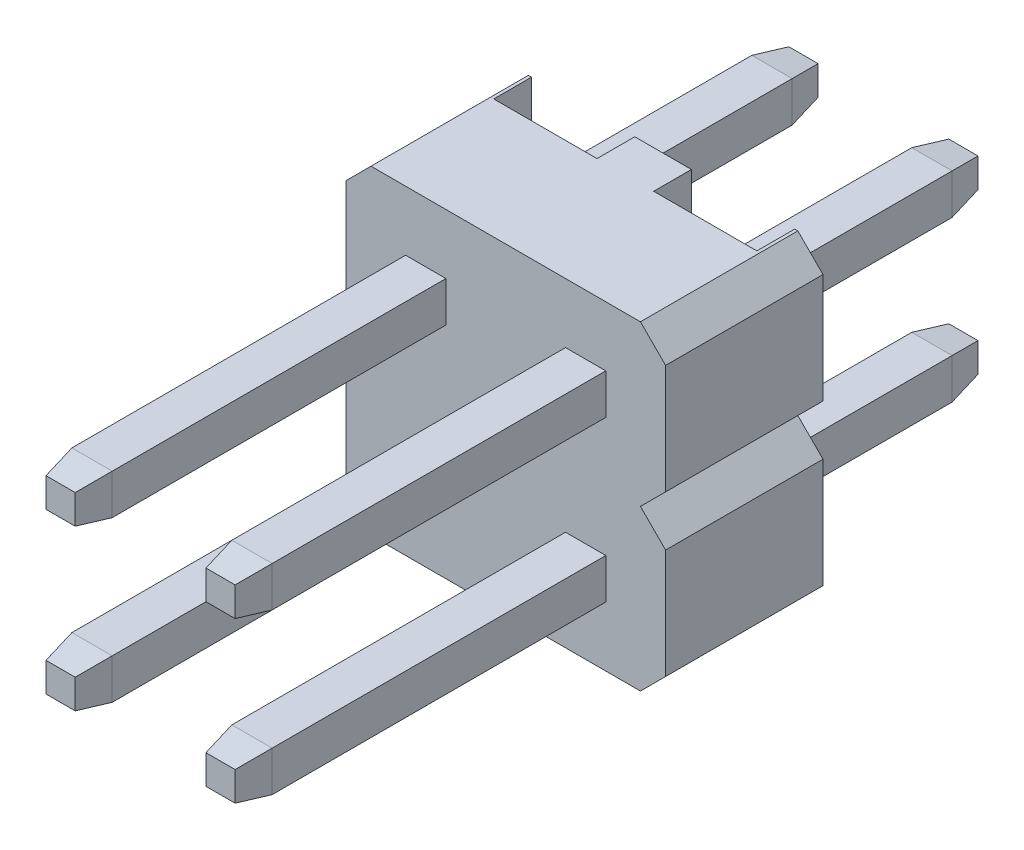
from build123d import *

# Parameters (mm, degrees)
SKETCH1_W             = 0.64
SKETCH1_H             = 0.64
BOSS_EXTRUDE1_DEPTH   = 5.3
BOSS_EXTRUDE1_2_DEPTH = 5.3
BOSS_EXTRUDE1_3_DEPTH = 5.3
BOSS_EXTRUDE1_4_DEPTH = 5.3
SKETCH2_W             = 0.64
SKETCH2_H             = 0.64
BOSS_EXTRUDE2_DEPTH   = 0.5
BOSS_EXTRUDE2_TAPER   = 10
BOSS_EXTRUDE3_DEPTH   = 2.5
SKETCH5_W             = 1.64
SKETCH5_H             = 5.08
CUT_EXTRUDE1_DEPTH    = 0.6
CUT_EXTRUDE3_DEPTH    = 3.5
SKETCH8_W             = 0.64
SKETCH8_H             = 0.64
BOSS_EXTRUDE4_DEPTH   = 3.6
BOSS_EXTRUDE4_2_DEPTH = 3.6
BOSS_EXTRUDE4_3_DEPTH = 3.6
BOSS_EXTRUDE4_4_DEPTH = 3.6
SKETCH9_W             = 0.64
SKETCH9_H             = 0.64
BOSS_EXTRUDE5_DEPTH   = 0.5
BOSS_EXTRUDE5_TAPER   = 10


with BuildPart() as part:
    # Sketch1 → Boss-Extrude1 (new body)
    with BuildSketch(Plane.XY):
        with Locations((-1.27, 1.27)):
            Rectangle(SKETCH1_W, SKETCH1_H)
    extrude(amount=BOSS_EXTRUDE1_DEPTH)



with BuildPart() as body_2:
    # Sketch1 → Boss-Extrude1 2 (new body)
    with BuildSketch(Plane.XY):
        with Locations((-1.27, -1.27)):
            Rectangle(SKETCH1_W, SKETCH1_H)
    extrude(amount=BOSS_EXTRUDE1_2_DEPTH)


with BuildPart() as body_3:
    # Sketch1 → Boss-Extrude1 3 (new body)
    with BuildSketch(Plane.XY):
        with Locations((1.27, 1.27)):
            Rectangle(SKETCH1_W, SKETCH1_H)
    extrude(amount=BOSS_EXTRUDE1_3_DEPTH)


with BuildPart() as body_4:
    # Sketch1 → Boss-Extrude1 4 (new body)
    with BuildSketch(Plane.XY):
        with Locations((1.27, -1.27)):
            Rectangle(SKETCH1_W, SKETCH1_H)
    extrude(amount=BOSS_EXTRUDE1_4_DEPTH)


with BuildPart() as part_1:
    add(part.part)

    add(body_2.part)  # Boss-Extrude2 merges body 2

    add(body_3.part)  # Boss-Extrude2 merges body 3

    add(body_4.part)  # Boss-Extrude2 merges body 4
    # Sketch2 → Boss-Extrude2 (add)
    with BuildSketch(Plane.XY.offset(5.3)):
        with Locations((-1.27, -1.27)):
            Rectangle(SKETCH2_W, SKETCH2_H)
        with Locations((-1.27, 1.27)):
            Rectangle(SKETCH2_W, SKETCH2_H)
        with Locations((1.27, -1.27)):
            Rectangle(SKETCH2_W, SKETCH2_H)
        with Locations((1.27, 1.27)):
            Rectangle(SKETCH2_W, SKETCH2_H)
    extrude(amount=BOSS_EXTRUDE2_DEPTH, taper=BOSS_EXTRUDE2_TAPER)


with BuildPart() as body_2_2:
    # Sketch3 → Boss-Extrude3 (new body)
    with BuildSketch(Plane.XY):
        Polygon((-2.14, 2.54), (2.14, 2.54), (2.54, 2.14), (2.54, -2.14), (2.14, -2.54), (-2.14, -2.54), (-2.54, -2.14), (-2.54, 2.14), align=None)
    extrude(amount=-BOSS_EXTRUDE3_DEPTH)

    # Sketch5 → Cut-Extrude1 (cut)
    with BuildSketch(Plane(origin=(0, 0, -2.5), x_dir=(-1, 0, 0), z_dir=(0, 0, -1))):
        with Locations((-1.27, 0)):
            Rectangle(SKETCH5_W, SKETCH5_H)
        with Locations((1.27, 0)):
            Rectangle(SKETCH5_W, SKETCH5_H)
    extrude(amount=-CUT_EXTRUDE1_DEPTH, mode=Mode.SUBTRACT)

    # Sketch7 → Cut-Extrude3 (cut, through all)
    with BuildSketch(Plane.XY):
        Polygon((2.54, 0), (2.54, 0.4), (2.14, 0), align=None)
        Polygon((2.54, 0), (2.14, 0), (2.54, -0.4), align=None)
        Polygon((-2.54, 0), (-2.54, -0.4), (-2.14, 0), align=None)
        Polygon((-2.54, 0.4), (-2.54, 0), (-2.14, 0), align=None)
    extrude(amount=-CUT_EXTRUDE3_DEPTH, mode=Mode.SUBTRACT)


with BuildPart() as body_3_2:
    # Sketch8 → Boss-Extrude4 (new body)
    with BuildSketch(Plane(origin=(0, 0, -1.9), x_dir=(-1, 0, 0), z_dir=(0, 0, -1))):
        with Locations((1.27, -1.27)):
            Rectangle(SKETCH8_W, SKETCH8_H)
    extrude(amount=BOSS_EXTRUDE4_DEPTH)



with BuildPart() as body_4_2:
    # Sketch8 → Boss-Extrude4 2 (new body)
    with BuildSketch(Plane(origin=(0, 0, -1.9), x_dir=(-1, 0, 0), z_dir=(0, 0, -1))):
        with Locations((1.27, 1.27)):
            Rectangle(SKETCH8_W, SKETCH8_H)
    extrude(amount=BOSS_EXTRUDE4_2_DEPTH)


with BuildPart() as body_5:
    # Sketch8 → Boss-Extrude4 3 (new body)
    with BuildSketch(Plane(origin=(0, 0, -1.9), x_dir=(-1, 0, 0), z_dir=(0, 0, -1))):
        with Locations((-1.27, 1.27)):
            Rectangle(SKETCH8_W, SKETCH8_H)
    extrude(amount=BOSS_EXTRUDE4_3_DEPTH)


with BuildPart() as body_6:
    # Sketch8 → Boss-Extrude4 4 (new body)
    with BuildSketch(Plane(origin=(0, 0, -1.9), x_dir=(-1, 0, 0), z_dir=(0, 0, -1))):
        with Locations((-1.27, -1.27)):
            Rectangle(SKETCH8_W, SKETCH8_H)
    extrude(amount=BOSS_EXTRUDE4_4_DEPTH)


with BuildPart() as body_3_2_1:
    add(body_3_2.part)

    add(body_4_2.part)  # Boss-Extrude5 merges body 4 2

    add(body_5.part)  # Boss-Extrude5 merges body 5

    add(body_6.part)  # Boss-Extrude5 merges body 6
    # Sketch9 → Boss-Extrude5 (add)
    with BuildSketch(Plane(origin=(0, 0, -5.5), x_dir=(-1, 0, 0), z_dir=(0, 0, -1))):
        with Locations((1.27, 1.27)):
            Rectangle(SKETCH9_W, SKETCH9_H)
        with Locations((1.27, -1.27)):
            Rectangle(SKETCH9_W, SKETCH9_H)
        with Locations((-1.27, -1.27)):
            Rectangle(SKETCH9_W, SKETCH9_H)
        with Locations((-1.27, 1.27)):
            Rectangle(SKETCH9_W, SKETCH9_H)
    extrude(amount=BOSS_EXTRUDE5_DEPTH, taper=BOSS_EXTRUDE5_TAPER)


solid = Compound([part_1.part, body_2_2.part, body_3_2_1.part])
